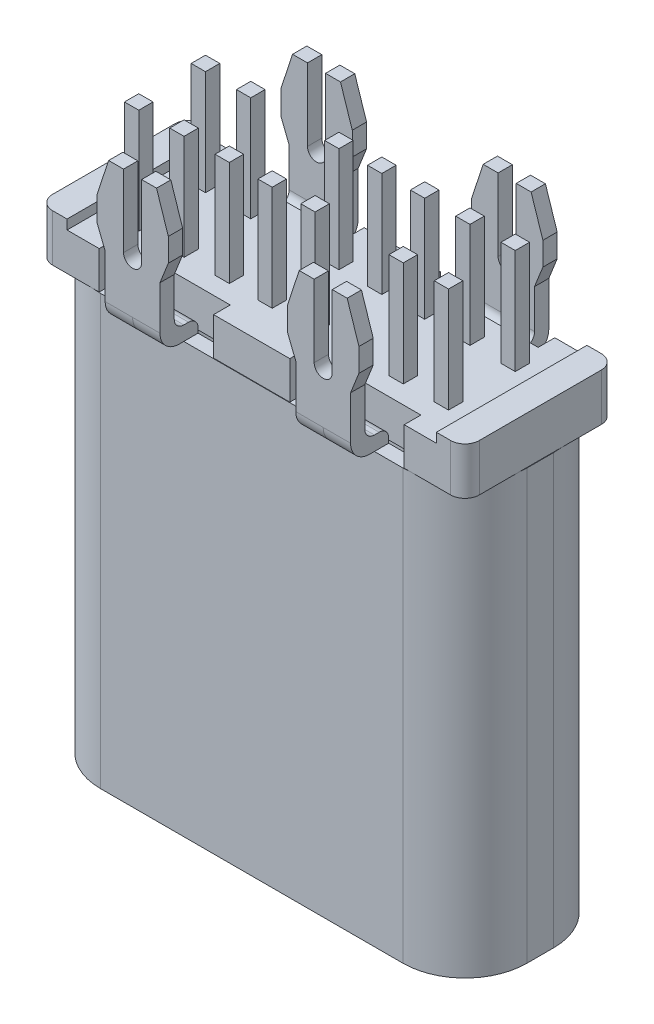
from build123d import *

# Parameters (mm, degrees)
EXTRUDE_1_DEPTH        = 9
EXTRUDE_3_DEPTH        = 0.75
CUT_EXTRUDE_2_DEPTH    = 4.66
FILLET_1_R             = 0.2
FILLET_2_R             = 0.4
FILLET_1_OF_MIRROR_1_R = 0.2
FILLET_2_OF_MIRROR_1_R = 0.4
CUT_EXTRUDE_4_DEPTH    = 13
EXTRUDE_2_DEPTH        = 0.99
SKETCH_6_W             = 7.75
SKETCH_6_H             = 3.16
CUT_EXTRUDE_3_DEPTH    = 0.2
FILLET_3_R             = 0.3
SKETCH_7_W             = 0.3
SKETCH_7_H             = 0.3
EXTRUDE_4_DEPTH        = 2.2
SKETCH_10_W            = 0.3
SKETCH_10_H            = 0.3
CUT_EXTRUDE_6_DEPTH    = 2.2
CHAMFER_1_SIZE         = 0.1


with BuildPart() as part:
    # 草图1 → 凸台-拉伸1 (new body)
    with BuildSketch(Plane(origin=(0, 0, 0), x_dir=(1, 0, 0), z_dir=(0, 1, 0))):
        with BuildLine():
            Line((4.475, -0.28), (4.475, 0.28))
            ThreePointArc((4.475, 0.28), (4.094238816, 1.199238816), (3.175, 1.58))
            Line((3.175, 1.58), (-3.175, 1.58))
            ThreePointArc((-3.175, 1.58), (-4.094238816, 1.199238816), (-4.475, 0.28))
            Line((-4.475, 0.28), (-4.475, -0.28))
            ThreePointArc((-4.475, -0.28), (-4.094238816, -1.199238816), (-3.175, -1.58))
            Line((-3.175, -1.58), (3.175, -1.58))
            ThreePointArc((3.175, -1.58), (4.094238816, -1.199238816), (4.475, -0.28))
        make_face()
        with BuildLine():
            Line((3.175, -1.28), (-3.175, -1.28))
            ThreePointArc((-3.175, -1.28), (-3.882106781, -0.987106781), (-4.175, -0.28))
            Line((-4.175, -0.28), (-4.175, 0.28))
            ThreePointArc((-4.175, 0.28), (-3.882106781, 0.987106781), (-3.175, 1.28))
            Line((-3.175, 1.28), (3.175, 1.28))
            ThreePointArc((3.175, 1.28), (3.882106781, 0.987106781), (4.175, 0.28))
            Line((4.175, 0.28), (4.175, -0.28))
            ThreePointArc((4.175, -0.28), (3.882106781, -0.987106781), (3.175, -1.28))
        make_face(mode=Mode.SUBTRACT)
    extrude(amount=EXTRUDE_1_DEPTH)

    # 草图4 → 凸台-拉伸3 (add)
    with BuildSketch(Plane(origin=(-2, 0, 0), x_dir=(0, 0, -1), z_dir=(1, 0, 0))):
        Polygon((-1.28, 9), (-1.28, 9.3), (-1.78, 9.3), (-1.78, 12), (-2.08, 12), (-2.08, 9), align=None)
    extrude_3 = extrude(amount=EXTRUDE_3_DEPTH)

    # 草图5 → 切除-拉伸2 (cut, through all)
    with BuildSketch(Plane.XY.offset(2.08)):
        with BuildLine():
            Line((-1.425567067, 9), (-1.425567067, 10.316689019))
            Line((-1.425567067, 10.316689019), (-1.25, 10.758217492))
            Line((-1.25, 10.758217492), (-1.25, 11.246001328))
            Line((-1.25, 11.246001328), (-1.497052629, 12))
            Line((-1.497052629, 12), (-1.810350983, 12))
            Line((-1.810350983, 12), (-1.810350983, 10.482783745))
            ThreePointArc((-1.810350983, 10.482783745), (-1.865897894, 10.34868164), (-2, 10.293134729))
            Line((-2, 10.293134729), (-2, 12.190600888))
            Line((-2, 12.190600888), (-1.008591798, 12.190600888))
            Line((-1.008591798, 12.190600888), (-1.008591798, 9))
            Line((-1.008591798, 9), (-1.425567067, 9))
        make_face()
    cut_extrude_2 = extrude(amount=-CUT_EXTRUDE_2_DEPTH, mode=Mode.SUBTRACT)

    # 圆角1
    fillet_1_edges = [part.edges().sort_by_distance(p)[0] for p in [
        (-1.712783534, 9.3, 1.78),
        (-1.712783534, 9.3, 1.28),
    ]]
    fillet(fillet_1_edges, radius=FILLET_1_R)

    # 圆角2
    fillet_2_edges = [part.edges().sort_by_distance(p)[0] for p in [
        (-1.712783534, 9, 2.08),
    ]]
    fillet(fillet_2_edges, radius=FILLET_2_R)

    # 镜向1: 凸台-拉伸3, 切除-拉伸2 across plane
    add(extrude_3.mirror(Plane(origin=(-2, 0, 0), x_dir=(0, 0, 1), z_dir=(1, 0, 0))))
    add(cut_extrude_2.mirror(Plane(origin=(-2, 0, 0), x_dir=(0, 0, 1), z_dir=(1, 0, 0))), mode=Mode.SUBTRACT)

    # 圆角1 of 镜向1
    fillet_1_of_mirror_1_edges = [part.edges().sort_by_distance(p)[0] for p in [
        (-2.287216466, 9.3, 1.78),
        (-2.287216466, 9.3, 1.28),
    ]]
    fillet(fillet_1_of_mirror_1_edges, radius=FILLET_1_OF_MIRROR_1_R)

    # 圆角2 of 镜向1
    fillet_2_of_mirror_1_edges = [part.edges().sort_by_distance(p)[0] for p in [
        (-2.287216466, 9, 2.08),
    ]]
    fillet(fillet_2_of_mirror_1_edges, radius=FILLET_2_OF_MIRROR_1_R)

    # 草图8 → 切除-拉伸4 (cut, through all)
    with BuildSketch(Plane.XZ):
        Polygon((0, 0), (-5.472025087, 0), (-5.472025087, -3.358036784), (5.622384952, -3.358036784), (5.622384952, 3.236317295), (0, 3.236317295), align=None)
    extrude(amount=-CUT_EXTRUDE_4_DEPTH, mode=Mode.SUBTRACT)

    # 镜向6: part across plane


with BuildPart() as part_1:
    add(part.part)
    add(part.part.mirror(Plane.XY))

    # 镜向9: part across plane


with BuildPart() as body_2:
    # 草图2 → 凸台-拉伸2 (new body)
    with BuildSketch(Plane(origin=(0, 9.01, 0), x_dir=(1, 0, 0), z_dir=(0, 1, 0))):
        Polygon((0, -1.58), (-0.8, -1.58), (-0.8, -1.23), (-3.2, -1.23), (-3.2, -1.58), (-4.475, -1.58), (-4.475, 1.58), (-3.2, 1.58), (-3.2, 1.23), (-0.8, 1.23), (-0.8, 1.58), (0, 1.58), align=None)
    extrude(amount=EXTRUDE_2_DEPTH)

    # 草图6 → 切除-拉伸3 (cut)
    with BuildSketch(Plane(origin=(0, 10, 0), x_dir=(1, 0, 0), z_dir=(0, 1, 0))):
        Rectangle(SKETCH_6_W, SKETCH_6_H)
    extrude(amount=-CUT_EXTRUDE_3_DEPTH, mode=Mode.SUBTRACT)

    # 圆角3
    fillet_3_edges = [body_2.edges().sort_by_distance(p)[0] for p in [
        (-4.475, 9.505, 1.58),
        (-4.475, 9.505, -1.58),
    ]]
    fillet(fillet_3_edges, radius=FILLET_3_R)

    # 草图7 → 凸台-拉伸4 (add)
    with BuildSketch(Plane(origin=(0, 9.8, 0), x_dir=(1, 0, 0), z_dir=(0, 1, 0))):
        with Locations((-0.45, -0.7)):
            Rectangle(SKETCH_7_W, SKETCH_7_H)
        with Locations((-0.45, 0.7)):
            Rectangle(SKETCH_7_W, SKETCH_7_H)
        with Locations((-2.3, -0.7)):
            Rectangle(SKETCH_7_W, SKETCH_7_H)
        with Locations((-2.3, 0.7)):
            Rectangle(SKETCH_7_W, SKETCH_7_H)
        with Locations((-3.25, 0.7)):
            Rectangle(SKETCH_7_W, SKETCH_7_H)
        with Locations((-1.35, -0.7)):
            Rectangle(SKETCH_7_W, SKETCH_7_H)
        with Locations((-3.25, -0.7)):
            Rectangle(SKETCH_7_W, SKETCH_7_H)
        with Locations((-1.35, 0.7)):
            Rectangle(SKETCH_7_W, SKETCH_7_H)
    extrude(amount=EXTRUDE_4_DEPTH)

    # Mirror 9 2: body 2 across plane


with BuildPart() as part_2:
    add(part_1.part)
    add(part_1.part.mirror(Plane(origin=(0, 12, 0), x_dir=(0, 0, 1), z_dir=(-1, 0, 0))))

    # 倒角1
    chamfer_1_edges = [part_2.edges().sort_by_distance(p)[0] for p in [
        (-4.175, 0, 0),
        (-3.882106781, 0, 0.987106781),
        (0, 0, 1.28),
        (-3.882106781, 0, -0.987106781),
        (0, 0, -1.28),
        (3.882106781, 0, -0.987106781),
        (4.175, 0, 0),
        (3.882106781, 0, 0.987106781),
    ]]
    chamfer(chamfer_1_edges, length=CHAMFER_1_SIZE)


with BuildPart() as body_2_1:
    add(body_2.part)
    add(body_2.part.mirror(Plane(origin=(0, 12, 0), x_dir=(0, 0, 1), z_dir=(-1, 0, 0))))

    # 草图10 → 切除-拉伸6 (cut)
    with BuildSketch(Plane(origin=(0, 12, 0), x_dir=(1, 0, 0), z_dir=(0, 1, 0))):
        with Locations((-1.35, 0.7)):
            Rectangle(SKETCH_10_W, SKETCH_10_H)
        with Locations((1.35, -0.7)):
            Rectangle(SKETCH_10_W, SKETCH_10_H)
    extrude(amount=-CUT_EXTRUDE_6_DEPTH, mode=Mode.SUBTRACT)


solid = Compound([part_2.part, body_2_1.part])
